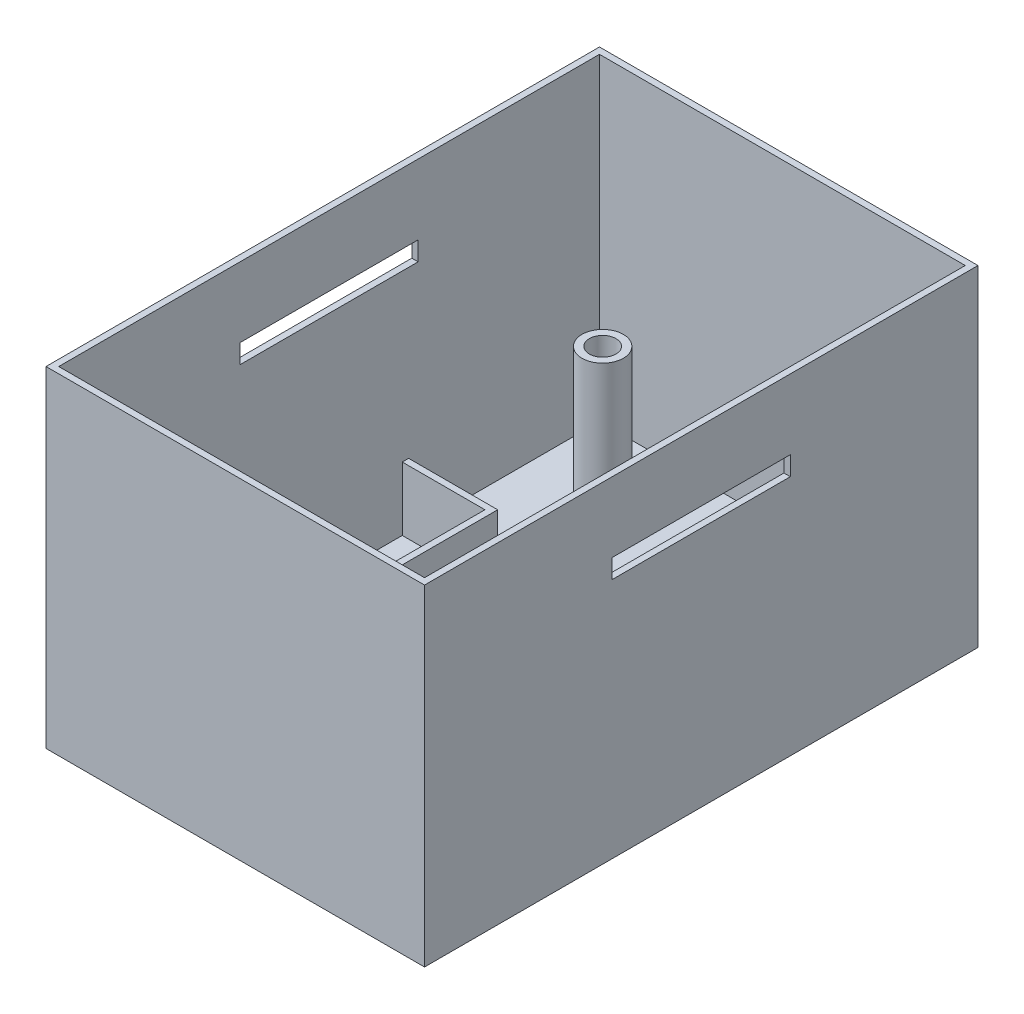
from build123d import *

# Parameters (mm, degrees)
CROQUIS1_W                = 59.5
CROQUIS1_H                = 87
SALIENTE_EXTRUIR1_DEPTH   = 50
SALIENTE_EXTRUIR2_DEPTH   = 10
CROQUIS1_5_R              = 3.25
CROQUIS1_5_R_2            = 2.1
SALIENTE_EXTRUIR3_DEPTH   = 20
SALIENTE_EXTRUIR3_2_DEPTH = 20
CROQUIS2_W                = 59.5
CROQUIS2_H                = 87
SALIENTE_EXTRUIR6_DEPTH   = 2
CORTAR_EXTRUIR3_START     = -10
CROQUIS9_R                = 2.1
CORTAR_EXTRUIR3_DEPTH     = 10
CORTAR_EXTRUIR4_DEPTH     = 100


with BuildPart() as part:
    # Croquis1 → Saliente-Extruir1 (new body)
    with BuildSketch(Plane(origin=(0, 0, 0), x_dir=(1, 0, 0), z_dir=(0, 1, 0))):
        Rectangle(CROQUIS1_W, CROQUIS1_H)
        Polygon((28.75, -42.5), (-28.75, -42.5), (-28.75, -35.5), (-28.75, -34.5), (-28.75, 11.5), (-28.75, 12.5), (-28.75, 42.5), (28.75, 42.5), align=None, mode=Mode.SUBTRACT)
    extrude(amount=SALIENTE_EXTRUIR1_DEPTH)

    # Croquis1_4 → Saliente-Extruir2 (add)
    with BuildSketch(Plane(origin=(0, 0, 0), x_dir=(1, 0, 0), z_dir=(0, 1, 0))):
        Polygon((-28.75, -34.5), (-28.75, -35.5), (-14.75, -35.5), (-14.75, 12.5), (-28.75, 12.5), (-28.75, 11.5), (-15.75, 11.5), (-15.75, -34.5), align=None)
    extrude(amount=SALIENTE_EXTRUIR2_DEPTH)



with BuildPart() as body_2:
    # Croquis1_5 → Saliente-Extruir3 (new body)
    with BuildSketch(Plane(origin=(0, 0, 0), x_dir=(1, 0, 0), z_dir=(0, 1, 0))):
        with Locations((19.75, -20)):
            Circle(CROQUIS1_5_R)
        with Locations((19.75, -20)):
            Circle(CROQUIS1_5_R_2, mode=Mode.SUBTRACT)
    extrude(amount=SALIENTE_EXTRUIR3_DEPTH)


with BuildPart() as body_3:
    # Croquis1_5 → Saliente-Extruir3 2 (new body)
    with BuildSketch(Plane(origin=(0, 0, 0), x_dir=(1, 0, 0), z_dir=(0, 1, 0))):
        with Locations((-18.75, 33)):
            Circle(CROQUIS1_5_R)
        with Locations((-18.75, 33)):
            Circle(CROQUIS1_5_R_2, mode=Mode.SUBTRACT)
    extrude(amount=SALIENTE_EXTRUIR3_2_DEPTH)


with BuildPart() as part_1:
    add(part.part)

    add(body_2.part)  # Saliente-Extruir6 merges body 2

    add(body_3.part)  # Saliente-Extruir6 merges body 3
    # Croquis2 → Saliente-Extruir6 (add)
    with BuildSketch(Plane.XZ):
        Rectangle(CROQUIS2_W, CROQUIS2_H)
    extrude(amount=SALIENTE_EXTRUIR6_DEPTH)

    # Croquis9 → Cortar-Extruir3 (cut)
    with BuildSketch(Plane(origin=(0, 0, 0), x_dir=(1, 0, 0), z_dir=(0, 1, 0)).offset(CORTAR_EXTRUIR3_START)):
        with Locations((-18.75, 33)):
            Circle(CROQUIS9_R)
        with Locations((19.75, -20)):
            Circle(CROQUIS9_R)
    extrude(amount=CORTAR_EXTRUIR3_DEPTH, mode=Mode.SUBTRACT)

    # Croquis10 → Cortar-Extruir4 (cut)
    with BuildSketch(Plane.ZY.offset(29.75)):
        Polygon((0, 39), (14, 39), (14, 36), (-14, 36), (-14, 39), align=None)
    extrude(amount=-CORTAR_EXTRUIR4_DEPTH, mode=Mode.SUBTRACT)


solid = part_1.part
